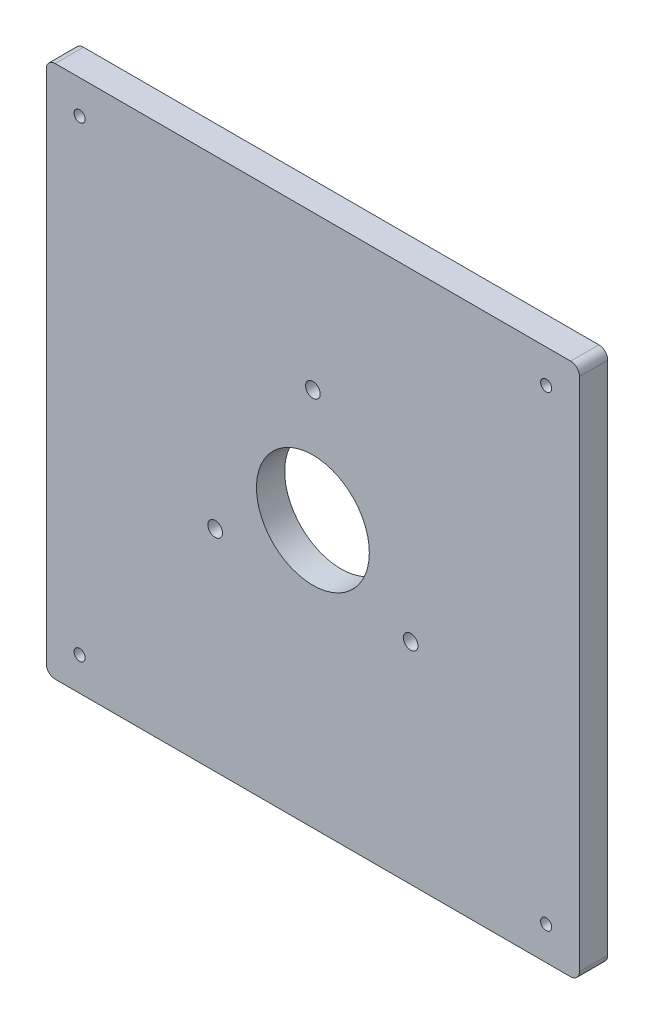
from build123d import *

# Parameters (mm, degrees)
ESQUISSE1_W             = 120
ESQUISSE1_H             = 120
ESQUISSE1_R             = 1.25
ESQUISSE1_R_2           = 12.7
BOSS_EXTRU_1_DEPTH      = 6.35
CONG_1_R                = 2
ESQUISSE2_R             = 1.65
ENL_V_MAT_EXTRU_1_DEPTH = 7.35


with BuildPart() as part:
    # Esquisse1 → Boss.-Extru.1 (new body)
    with BuildSketch(Plane.XY):
        with Locations((60, 60)):
            Rectangle(ESQUISSE1_W, ESQUISSE1_H)
        with Locations((7.5, 112.5)):
            Circle(ESQUISSE1_R, mode=Mode.SUBTRACT)
        with Locations((112.5, 112.5)):
            Circle(ESQUISSE1_R, mode=Mode.SUBTRACT)
        with Locations((112.5, 7.5)):
            Circle(ESQUISSE1_R, mode=Mode.SUBTRACT)
        with Locations((7.5, 7.5)):
            Circle(ESQUISSE1_R, mode=Mode.SUBTRACT)
        with Locations((60, 60)):
            Circle(ESQUISSE1_R_2, mode=Mode.SUBTRACT)
    extrude(amount=BOSS_EXTRU_1_DEPTH)

    # Congé1
    cong_1_edges = [part.edges().sort_by_distance(p)[0] for p in [
        (0, 120, 3.175),
        (120, 120, 3.175),
        (120, 0, 3.175),
        (0, 0, 3.175),
    ]]
    fillet(cong_1_edges, radius=CONG_1_R)

    # Esquisse2 → Enlèv. mat.-Extru.1 (cut, through all)
    with BuildSketch(Plane.XY.offset(6.35)):
        with Locations((60, 85.4)):
            Circle(ESQUISSE2_R)
        with Locations((38.002954744, 47.3)):
            Circle(ESQUISSE2_R)
        with Locations((81.997045256, 47.3)):
            Circle(ESQUISSE2_R)
    extrude(amount=-ENL_V_MAT_EXTRU_1_DEPTH, mode=Mode.SUBTRACT)


solid = part.part
